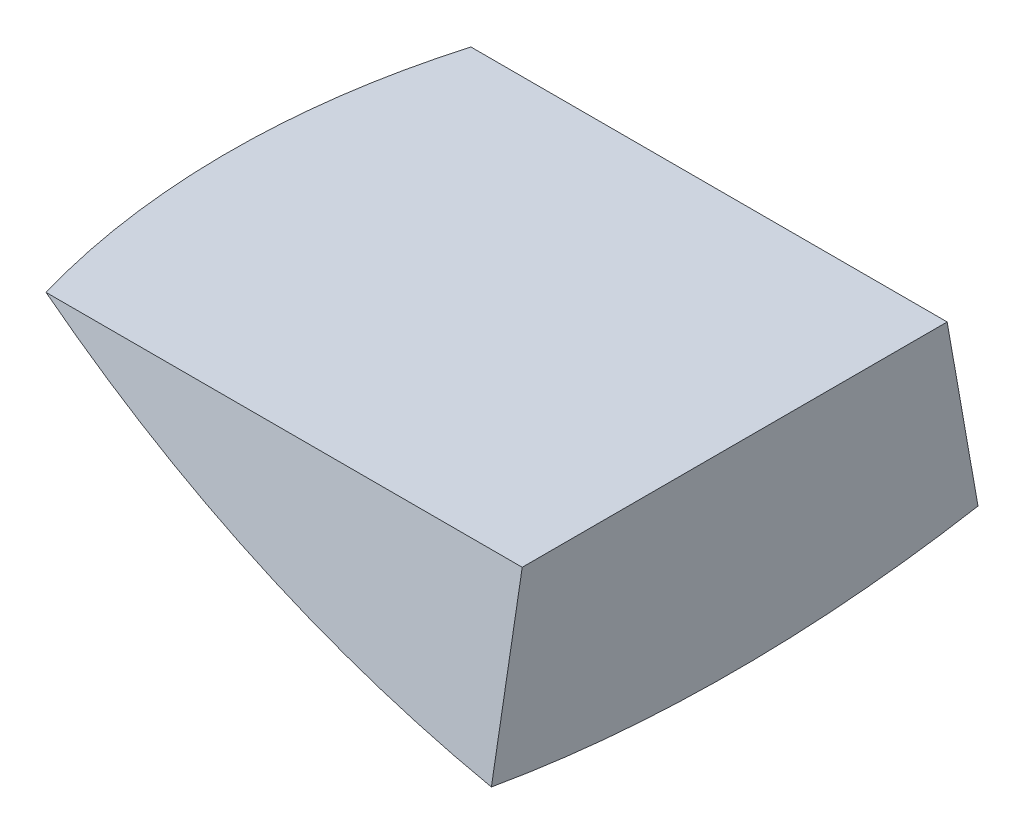
from build123d import *

# Parameters (mm, degrees)
REVOLVE1_ANGLE     = 20
SKETCH2_W          = 414.694447971
SKETCH2_H          = 30.87278354
CUT_EXTRUDE1_DEPTH = 249.770836259


with BuildPart() as part:
    # Sketch1 → Revolve1 (revolve, symmetric)
    with BuildSketch(Plane.XY) as revolve1_sk:
        with BuildLine():
            Line((-110.266592819, -625.352923163), (-110.266592819, -523.752923163))
            Line((-110.266592819, -523.752923163), (-359.037429077, -523.752923163))
            ThreePointArc((-359.037429077, -523.752923163), (-240.087913569, -587.86290388), (-110.266592819, -625.352923163))
        make_face()
    revolve(axis=Axis((22.053318564, 9.647076837, 0), (-1, 0, 0)), revolution_arc=REVOLVE1_ANGLE / 2)
    revolve(revolve1_sk.sketch, axis=Axis((22.053318564, 9.647076837, 0), (1, 0, 0)), revolution_arc=REVOLVE1_ANGLE / 2)

    # Sketch2 → Cut-Extrude1 (cut, through all)
    with BuildSketch(Plane(origin=(-110.266592819, 0, 0), x_dir=(0, 0, -1), z_dir=(1, 0, 0))):
        with Locations((-9.950026192, -521.016531393)):
            Rectangle(SKETCH2_W, SKETCH2_H)
    extrude(amount=-CUT_EXTRUDE1_DEPTH, mode=Mode.SUBTRACT)


solid = part.part
